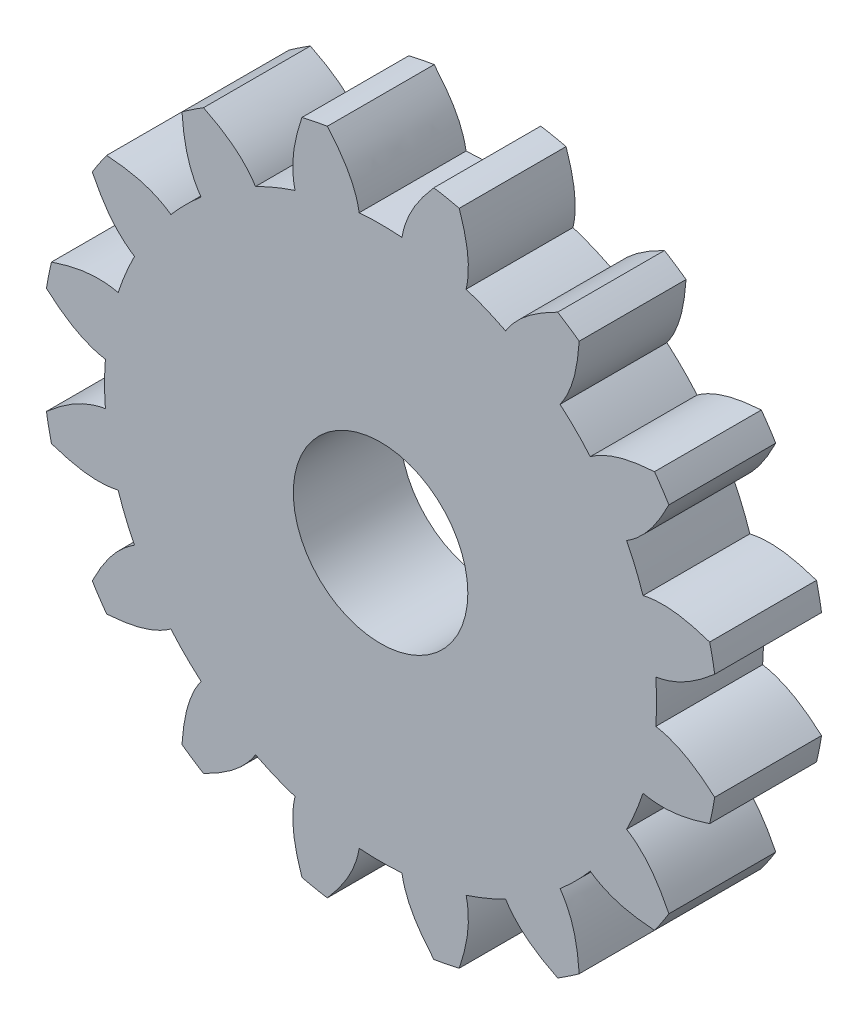
from build123d import *

# Parameters (mm, degrees)
SKETCH1_R           = 9.5
SKETCH1_R_2         = 2.45
BOSS_EXTRUDE1_DEPTH = 3
CUT_EXTRUDE1_DEPTH  = 10
CIRPATTERN1_COUNT   = 16


with BuildPart() as part:
    # Sketch1 → Boss-Extrude1 (new body)
    with BuildSketch(Plane.XY):
        Circle(SKETCH1_R)
        Circle(SKETCH1_R_2, mode=Mode.SUBTRACT)
    extrude(amount=BOSS_EXTRUDE1_DEPTH)

    # Sketch6 → Cut-Extrude1 (cut)
    with BuildSketch(Plane(origin=(0, 0, 0), x_dir=(-1, 0, 0), z_dir=(0, 0, -1))):
        with BuildLine():
            ThreePointArc((-0.6, 7.726739286), (0, 7.75), (0.6, 7.726739286))
            add(Edge.make_bspline(
                [(1.495318178, 9.381578947), (1.036824569, 8.853460115), (0.705300974, 8.349634332), (0.6, 7.726739286)],
                knots=[0, 0, 0, 0, 1, 1, 1, 1], degree=3))
            ThreePointArc((1.495318178, 9.381578947), (0, 9.5), (-1.495318178, 9.381578947))
            add(Edge.make_bspline(
                [(-1.495318178, 9.381578947), (-1.036824569, 8.853460115), (-0.705300974, 8.349634332), (-0.6, 7.726739286)],
                knots=[0, 0, 0, 0, 1, 1, 1, 1], degree=3))
        make_face()
    cut_extrude1 = extrude(amount=-CUT_EXTRUDE1_DEPTH, mode=Mode.SUBTRACT)

    # CirPattern1: Cut-Extrude1 ×16 about axis
    cirpattern1_axis = Axis((0, 0, 0), (0, 0, 1))
    for i in range(1, CIRPATTERN1_COUNT):
        add(cut_extrude1.rotate(cirpattern1_axis, i * 360 / CIRPATTERN1_COUNT), mode=Mode.SUBTRACT)


solid = part.part
